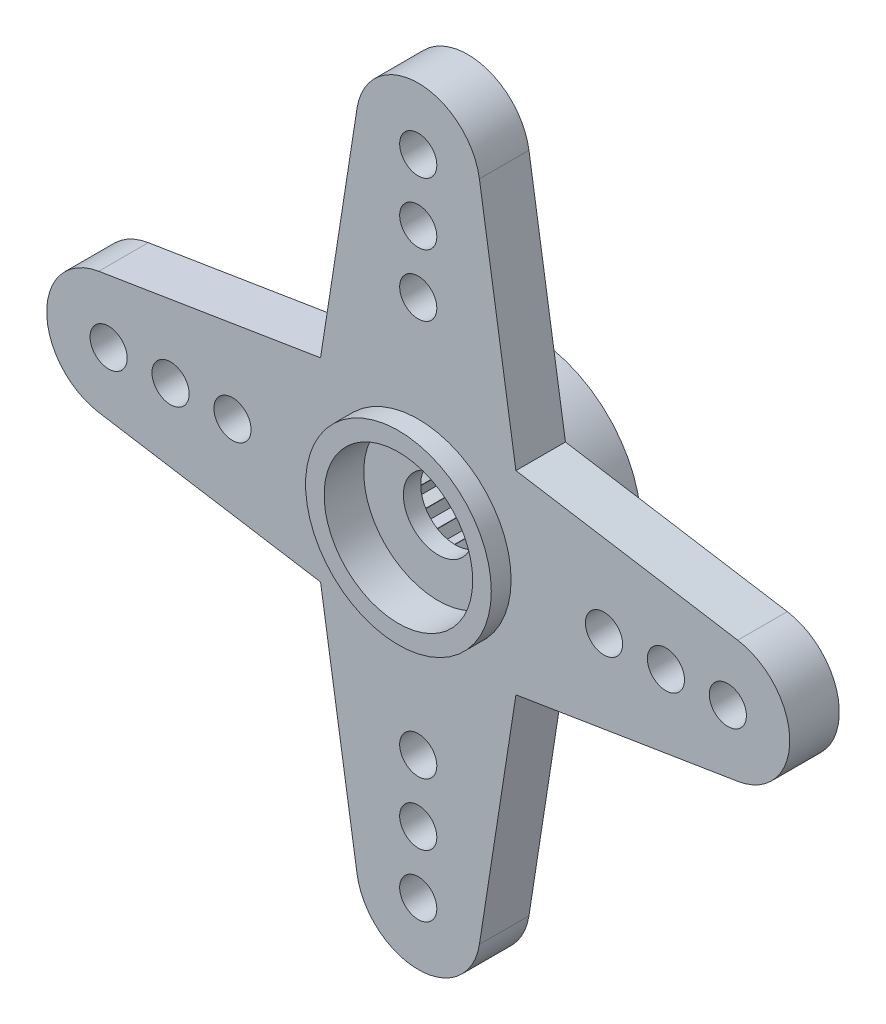
from build123d import *

# Parameters (mm, degrees)
ESQUISSE1_R                  = 4.5
BOSS_EXTRU_1_DEPTH           = 3
BOSS_EXTRU_2_START           = -0.5
ESQUISSE2_R                  = 0.75
BOSS_EXTRU_2_DEPTH           = 2
R_P_TITION_CIRCULAIRE1_COUNT = 2
ESQUISSE3_R                  = 0.75
BOSS_EXTRU_3_DEPTH           = 2
R_P_TITION_CIRCULAIRE2_COUNT = 2
ESQUISSE5_R                  = 4.5
ESQUISSE5_R_2                = 1.4
BOSS_EXTRU_4_DEPTH           = 0.7
ESQUISSE6_R                  = 4.5
ESQUISSE6_R_2                = 3
BOSS_EXTRU_5_DEPTH           = 0.8
ESQUISSE7_R                  = 3.75
ESQUISSE7_R_2                = 3
BOSS_EXTRU_6_DEPTH           = 0.8


with BuildPart() as part:
    # Esquisse1 → Boss.-Extru.1 (new body)
    with BuildSketch(Plane.XY):
        Circle(ESQUISSE1_R)
        Polygon((2.011577371, -1.550856692), (2.011577371, -2.011577371), (1.550856692, -2.011577371), (1.541643286, -2.018647066), (1.4224, -2.463669069), (0.977377998, -2.344425783), (0.966648759, -2.348869979), (0.73628842, -2.747865791), (0.337292608, -2.517505451), (0.325778716, -2.519021284), (0, -2.8448), (-0.325778716, -2.519021284), (-0.337292608, -2.517505451), (-0.73628842, -2.747865791), (-0.966648759, -2.348869979), (-0.977377998, -2.344425783), (-1.4224, -2.463669069), (-1.541643286, -2.018647066), (-1.550856692, -2.011577371), (-2.011577371, -2.011577371), (-2.011577371, -1.550856692), (-2.018647066, -1.541643286), (-2.463669069, -1.4224), (-2.344425783, -0.977377998), (-2.348869979, -0.966648759), (-2.747865791, -0.73628842), (-2.517505451, -0.337292608), (-2.519021284, -0.325778716), (-2.8448, 0), (-2.519021284, 0.325778716), (-2.517505451, 0.337292608), (-2.747865791, 0.73628842), (-2.348869979, 0.966648759), (-2.344425783, 0.977377998), (-2.463669069, 1.4224), (-2.018647066, 1.541643286), (-2.011577371, 1.550856692), (-2.011577371, 2.011577371), (-1.550856692, 2.011577371), (-1.541643286, 2.018647066), (-1.4224, 2.463669069), (-0.977377998, 2.344425783), (-0.966648759, 2.348869979), (-0.73628842, 2.747865791), (-0.337292608, 2.517505451), (-0.325778716, 2.519021284), (0, 2.8448), (0.325778716, 2.519021284), (0.337292608, 2.517505451), (0.73628842, 2.747865791), (0.966648759, 2.348869979), (0.977377998, 2.344425783), (1.4224, 2.463669069), (1.541643286, 2.018647066), (1.550856692, 2.011577371), (2.011577371, 2.011577371), (2.011577371, 1.550856692), (2.018647066, 1.541643286), (2.463669069, 1.4224), (2.344425783, 0.977377998), (2.348869979, 0.966648759), (2.747865791, 0.73628842), (2.517505451, 0.337292608), (2.519021284, 0.325778716), (2.8448, 0), (2.519021284, -0.325778716), (2.517505451, -0.337292608), (2.747865791, -0.73628842), (2.348869979, -0.966648759), (2.344425783, -0.977377998), (2.463669069, -1.4224), (2.018647066, -1.541643286), align=None, mode=Mode.SUBTRACT)
    extrude(amount=BOSS_EXTRU_1_DEPTH)

    # Esquisse2 → Boss.-Extru.2 (add)
    with BuildSketch(Plane.XY.offset(3).offset(BOSS_EXTRU_2_START)):
        with BuildLine():
            Line((-12.9, 2.467792536), (-0.72, 4.442026565))
            ThreePointArc((-0.72, 4.442026565), (-4.5, 0), (-0.72, -4.442026565))
            Line((-0.72, -4.442026565), (-12.9, -2.467792536))
            ThreePointArc((-12.9, -2.467792536), (-15, 0), (-12.9, 2.467792536))
        make_face()
        with Locations((-12.5, 0)):
            Circle(ESQUISSE2_R, mode=Mode.SUBTRACT)
        with Locations((-10, 0)):
            Circle(ESQUISSE2_R, mode=Mode.SUBTRACT)
        with Locations((-7.5, 0)):
            Circle(ESQUISSE2_R, mode=Mode.SUBTRACT)
    boss_extru_2 = extrude(amount=BOSS_EXTRU_2_DEPTH)

    # Répétition circulaire1: Boss.-Extru.2 ×2 about axis
    r_p_tition_circulaire1_axis = Axis((0, 0, 0), (0, 0, 1))
    for i in range(1, R_P_TITION_CIRCULAIRE1_COUNT):
        add(boss_extru_2.rotate(r_p_tition_circulaire1_axis, i * 360 / R_P_TITION_CIRCULAIRE1_COUNT))

    # Esquisse3 → Boss.-Extru.3 (add)
    with BuildSketch(Plane.XY.offset(4.5)):
        with BuildLine():
            Line((4.446426662, -0.692307692), (2.470237034, -13.384615385))
            ThreePointArc((2.470237034, -13.384615385), (0, -15.5), (-2.470237034, -13.384615385))
            Line((-2.470237034, -13.384615385), (-4.446426662, -0.692307692))
            ThreePointArc((-4.446426662, -0.692307692), (0, -4.5), (4.446426662, -0.692307692))
        make_face()
        with Locations((0, -13)):
            Circle(ESQUISSE3_R, mode=Mode.SUBTRACT)
        with Locations((0, -10.5)):
            Circle(ESQUISSE3_R, mode=Mode.SUBTRACT)
        with Locations((0, -8)):
            Circle(ESQUISSE3_R, mode=Mode.SUBTRACT)
    boss_extru_3 = extrude(amount=-BOSS_EXTRU_3_DEPTH)

    # Répétition circulaire2: Boss.-Extru.3 ×2 about axis
    r_p_tition_circulaire2_axis = Axis((0, 0, 0), (0, 0, 1))
    for i in range(1, R_P_TITION_CIRCULAIRE2_COUNT):
        add(boss_extru_3.rotate(r_p_tition_circulaire2_axis, i * 360 / R_P_TITION_CIRCULAIRE2_COUNT))

    # Esquisse5 → Boss.-Extru.4 (add)
    with BuildSketch(Plane.XY.offset(3)):
        Circle(ESQUISSE5_R)
        Circle(ESQUISSE5_R_2, mode=Mode.SUBTRACT)
    extrude(amount=BOSS_EXTRU_4_DEPTH)

    # Esquisse6 → Boss.-Extru.5 (add)
    with BuildSketch(Plane.XY.offset(3.7)):
        Circle(ESQUISSE6_R)
        Circle(ESQUISSE6_R_2, mode=Mode.SUBTRACT)
    extrude(amount=BOSS_EXTRU_5_DEPTH)

    # Esquisse7 → Boss.-Extru.6 (add)
    with BuildSketch(Plane.XY.offset(4.5)):
        Circle(ESQUISSE7_R)
        Circle(ESQUISSE7_R_2, mode=Mode.SUBTRACT)
    extrude(amount=BOSS_EXTRU_6_DEPTH)


solid = part.part
